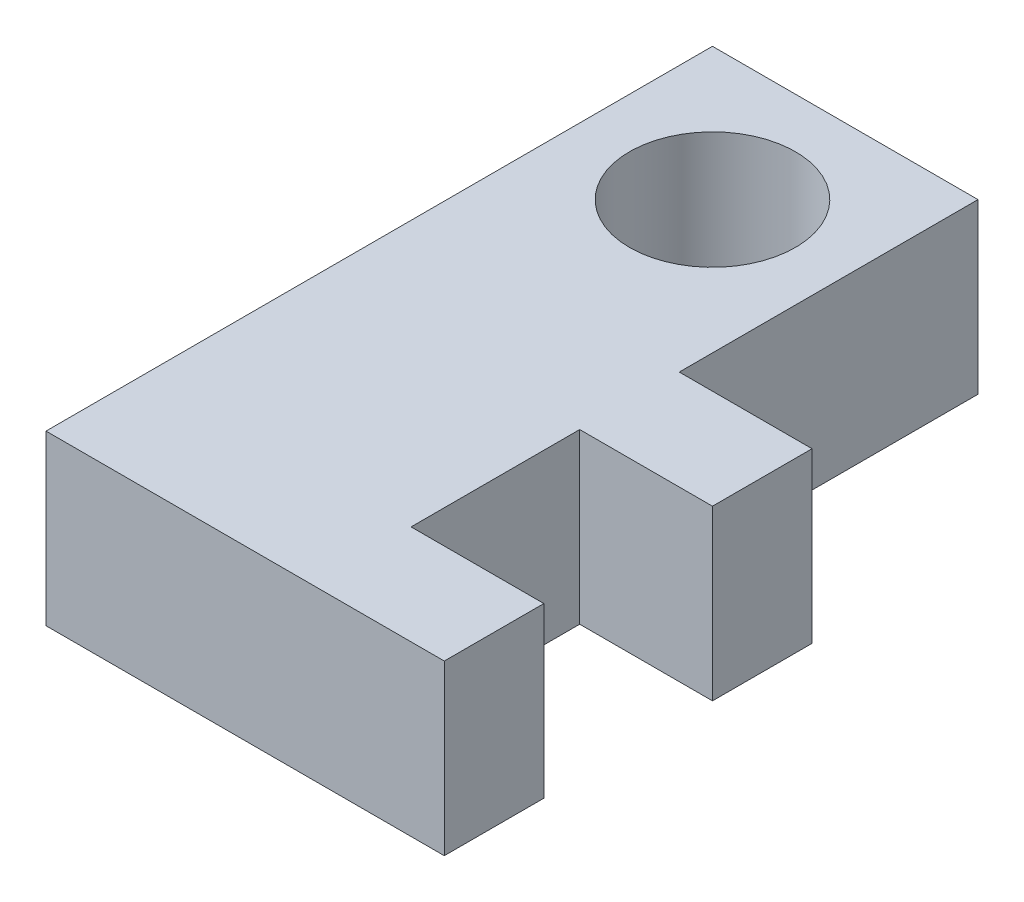
from build123d import *

# Parameters (mm, degrees)
SKETCH1_W           = 8
SKETCH1_H           = 12
SKETCH1_R           = 2.5
BOSS_EXTRUDE1_DEPTH = 5.08
SKETCH2_W           = 4
SKETCH2_H           = 3
BOSS_EXTRUDE2_DEPTH = 5.08


with BuildPart() as part:
    # Sketch1 → Boss-Extrude1 (new body)
    with BuildSketch(Plane(origin=(0, 0, 0), x_dir=(1, 0, 0), z_dir=(0, 1, 0))):
        with Locations((0, -2)):
            Rectangle(SKETCH1_W, SKETCH1_H)
        Circle(SKETCH1_R, mode=Mode.SUBTRACT)
    extrude(amount=BOSS_EXTRUDE1_DEPTH)

    # Sketch2 → Boss-Extrude2 (add)
    with BuildSketch(Plane(origin=(0, 5.08, 0), x_dir=(1, 0, 0), z_dir=(0, 1, 0))):
        with Locations((6, -6.5)):
            Rectangle(SKETCH2_W, SKETCH2_H)
        Polygon((-4, -8), (-4, -16.08), (8, -16.08), (8, -13.08), (4, -13.08), (4, -8), align=None)
    extrude(amount=-BOSS_EXTRUDE2_DEPTH)


solid = part.part
